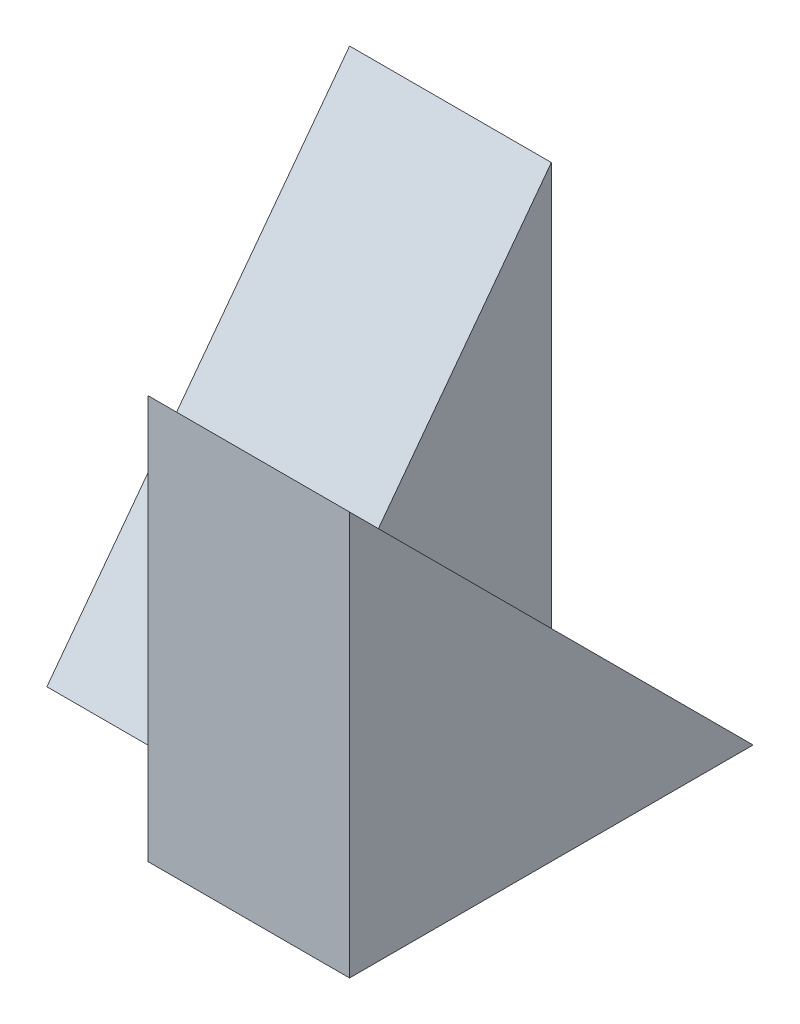
from build123d import *

# Parameters (mm, degrees)
SKETCH1_W           = 4
SKETCH1_H           = 4
BOSS_EXTRUDE1_DEPTH = 2
SKETCH2_W           = 3
SKETCH2_H           = 4
BOSS_EXTRUDE2_DEPTH = 2
CUT_EXTRUDE1_DEPTH  = 2
CUT_EXTRUDE2_DEPTH  = 2


with BuildPart() as part:
    # Sketch1 → Boss-Extrude1 (new body)
    with BuildSketch(Plane(origin=(0, 0, 0), x_dir=(0, 0, -1), z_dir=(1, 0, 0))):
        with Locations((2, 2)):
            Rectangle(SKETCH1_W, SKETCH1_H)
    extrude(amount=BOSS_EXTRUDE1_DEPTH)

    # Sketch2 → Boss-Extrude2 (add)
    with BuildSketch(Plane.ZY):
        with Locations((-2.5, 2)):
            Rectangle(SKETCH2_W, SKETCH2_H)
    extrude(amount=BOSS_EXTRUDE2_DEPTH)

    # Sketch3 → Cut-Extrude1 (cut)
    with BuildSketch(Plane(origin=(2, 0, 0), x_dir=(0, 0, -1), z_dir=(1, 0, 0))):
        Polygon((4, 0), (0, 4), (4, 4), align=None)
    extrude(amount=-CUT_EXTRUDE1_DEPTH, mode=Mode.SUBTRACT)

    # Sketch4 → Cut-Extrude2 (cut)
    with BuildSketch(Plane.ZY.offset(2)):
        Polygon((-1, 0), (-4, 4), (-1, 4), align=None)
    extrude(amount=-CUT_EXTRUDE2_DEPTH, mode=Mode.SUBTRACT)


solid = part.part
